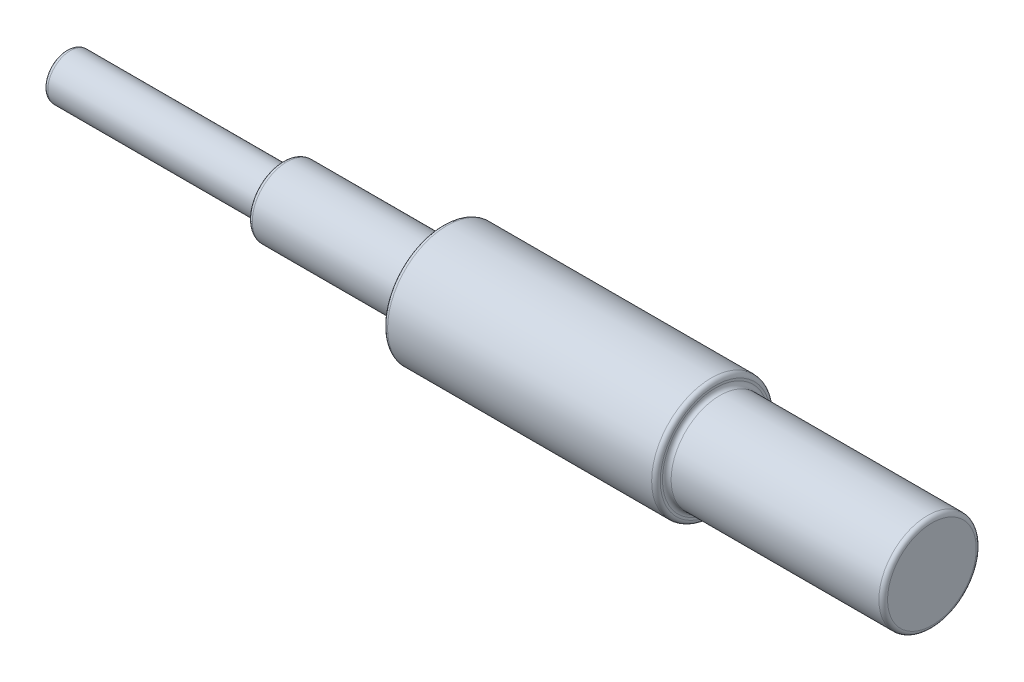
from build123d import *

# Parameters (mm, degrees)
FILLET4_R = 2
FILLET5_R = 2


with BuildPart() as part:
    # Sketch1 → Revolve1 (revolve)
    with BuildSketch(Plane(origin=(0, 0, 0), x_dir=(1, 0, 0), z_dir=(0, 1, 0))):
        Polygon((0, 0), (0, 10.5), (100, 10.5), (100, 16), (173.994186745, 16), (173.994186745, 27.5), (200, 27.5), (300, 27.5), (300, 22.5), (400, 22.5), (400, 0), align=None)
    revolve(axis=Axis((0, 0, 0), (1, 0, 0)))

    # Fillet4
    fillet4_edges = [part.edges().sort_by_distance(p)[0] for p in [
        (0, 0, 10.5),
    ]]
    fillet(fillet4_edges, radius=FILLET4_R)

    # Fillet5
    fillet5_edges = [part.edges().sort_by_distance(p)[0] for p in [
        (100, 0, 16),
        (173.994186745, 0, 16),
        (173.994186745, 0, 27.5),
        (300, 0, 27.5),
        (300, 0, 22.5),
        (400, 0, 22.5),
        (100, 0, 10.5),
    ]]
    fillet(fillet5_edges, radius=FILLET5_R)


solid = part.part
